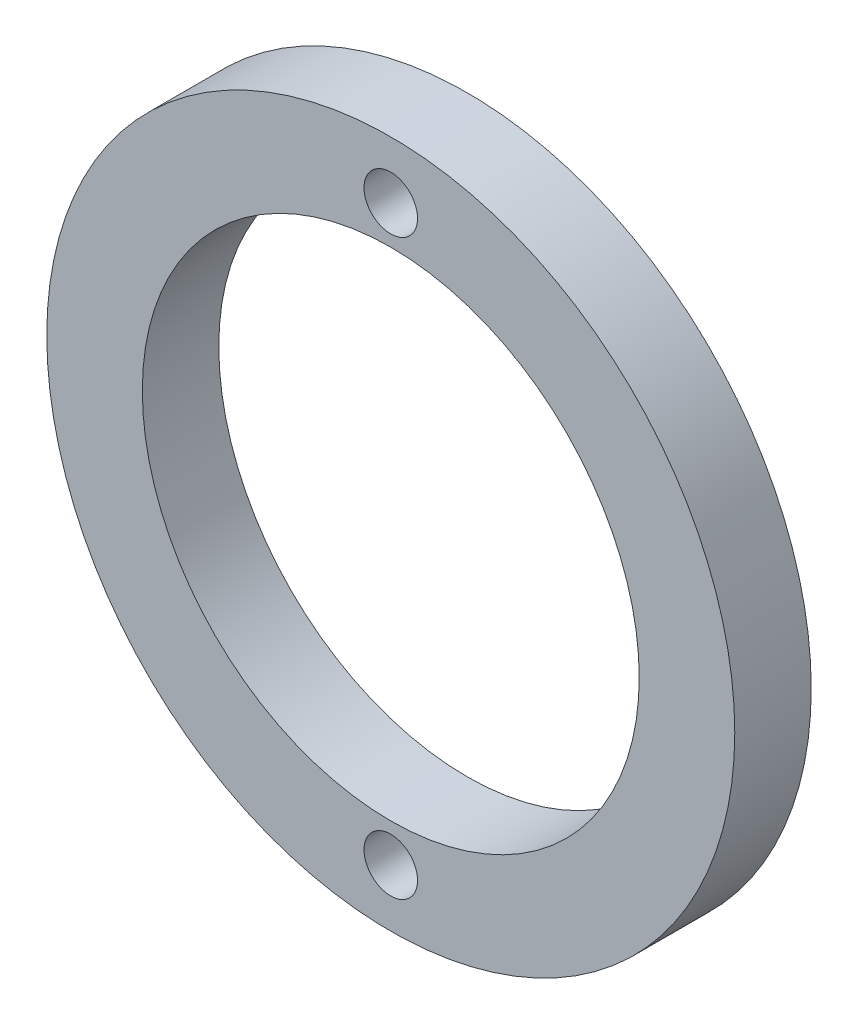
from build123d import *

# Parameters (mm, degrees)
SKETCH1_R             = 11.43
SKETCH1_R_2           = 8.255
BOSS_EXTRUDE1_DEPTH   = 2.54
F_2_56_TAPPED_HOLE1_D = 1.778


with BuildPart() as part:
    # Sketch1 → Boss-Extrude1 (new body)
    with BuildSketch(Plane.XY):
        Circle(SKETCH1_R)
        Circle(SKETCH1_R_2, mode=Mode.SUBTRACT)
    extrude(amount=BOSS_EXTRUDE1_DEPTH)

    # #2-56 Tapped Hole1 (through all)
    with Locations(Plane.XY.offset(2.54)):
        with Locations((0, 9.525)):
            f_2_56_tapped_hole1 = Hole(F_2_56_TAPPED_HOLE1_D / 2)

    # Mirror1: #2-56 Tapped Hole1 across plane
    add(f_2_56_tapped_hole1.mirror(Plane.ZX), mode=Mode.SUBTRACT)


solid = part.part
